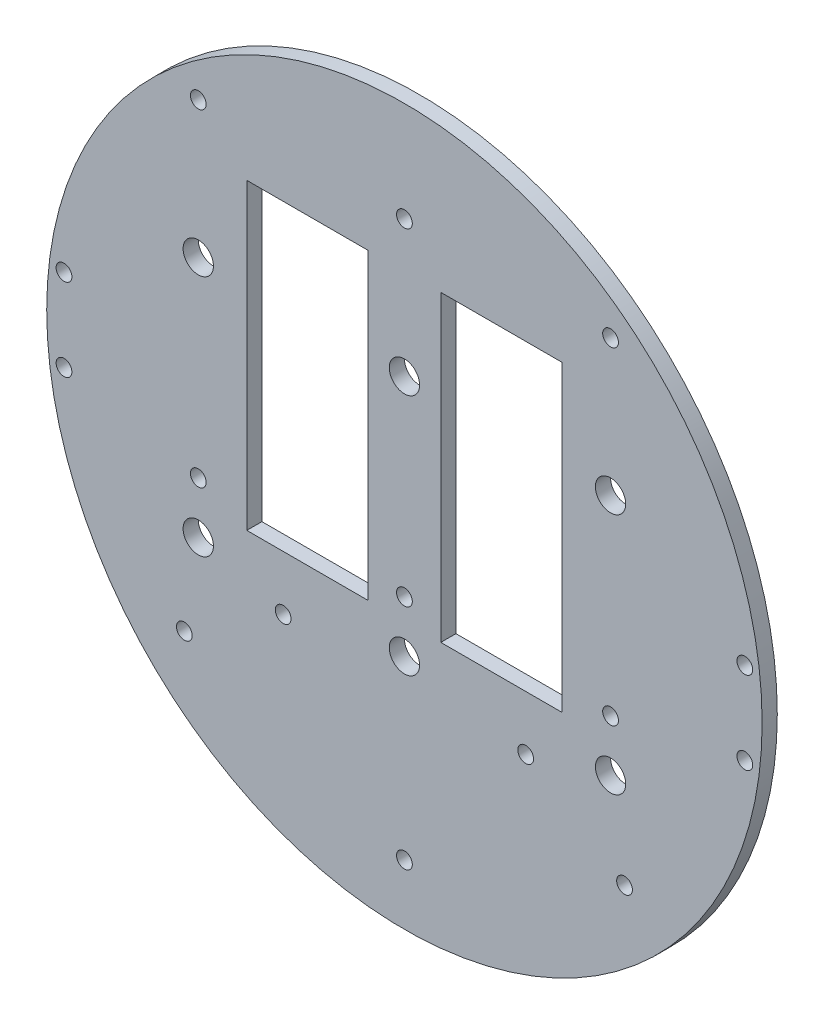
from build123d import *

# Parameters (mm, degrees)
SKETCH1_R           = 1.651
BOSS_EXTRUDE2_DEPTH = 3.175
SKETCH5_W           = 36.105919561
SKETCH5_H           = 30.801250688
SKETCH5_W_2         = 35.958513686
SKETCH5_H_2         = 33.469345806
BOSS_EXTRUDE4_DEPTH = 3.175
SKETCH11_R          = 1.651
CUT_EXTRUDE7_DEPTH  = 4.175
BOSS_EXTRUDE6_DEPTH = 3.175
SKETCH13_R          = 3.175
CUT_EXTRUDE8_DEPTH  = 21.59
SKETCH14_W          = 25.4
SKETCH14_H          = 63.5
CUT_EXTRUDE9_DEPTH  = 46.482
SKETCH15_R          = 1.651
CUT_EXTRUDE10_DEPTH = 150.876


with BuildPart() as part:
    # Sketch1 → Boss-Extrude2 (new body)
    with BuildSketch(Plane.XY):
        with BuildLine():
            Line((-73.845886141, 12.7), (-56.065886141, 12.7))
            Line((-56.065886141, 12.7), (-56.065886141, -12.7))
            Line((-56.065886141, -12.7), (-73.845886141, -12.7))
            ThreePointArc((-73.845886141, -12.7), (0, -74.93), (73.845886141, -12.7))
            Line((73.845886141, -12.7), (56.065886141, -12.7))
            Line((56.065886141, -12.7), (56.065886141, 12.7))
            Line((56.065886141, 12.7), (73.845886141, 12.7))
            ThreePointArc((73.845886141, 12.7), (0, 74.93), (-73.845886141, 12.7))
        make_face()
        with Locations((-45.466, 11.049)):
            Circle(SKETCH1_R, mode=Mode.SUBTRACT)
        with Locations((-20.067270032, 10.795)):
            Circle(SKETCH1_R, mode=Mode.SUBTRACT)
        with Locations((-20.067270032, -10.795)):
            Circle(SKETCH1_R, mode=Mode.SUBTRACT)
        with Locations((-45.466, -11.049)):
            Circle(SKETCH1_R, mode=Mode.SUBTRACT)
        with Locations((45.466, -11.049)):
            Circle(SKETCH1_R, mode=Mode.SUBTRACT)
        with Locations((20.067270032, -10.795)):
            Circle(SKETCH1_R, mode=Mode.SUBTRACT)
        with Locations((20.067270032, 10.795)):
            Circle(SKETCH1_R, mode=Mode.SUBTRACT)
        with Locations((45.466, 11.049)):
            Circle(SKETCH1_R, mode=Mode.SUBTRACT)
    extrude(amount=BOSS_EXTRUDE2_DEPTH)

    # Sketch5 → Boss-Extrude4 (add)
    with BuildSketch(Plane(origin=(0, 0, 0), x_dir=(-1, 0, 0), z_dir=(0, 0, -1))):
        with Locations((34.78484389, -0.38515144)):
            Rectangle(SKETCH5_W, SKETCH5_H)
        with Locations((-32.830563904, 0.948896119)):
            Rectangle(SKETCH5_W_2, SKETCH5_H_2)
    extrude(amount=-BOSS_EXTRUDE4_DEPTH)

    # Sketch11 → Cut-Extrude7 (cut, through all)
    with BuildSketch(Plane(origin=(0, 0, 0), x_dir=(-1, 0, 0), z_dir=(0, 0, -1))):
        with Locations((43.18, 53.975)):
            Circle(SKETCH11_R)
        with Locations((0, 53.975)):
            Circle(SKETCH11_R)
        with Locations((0, -14.605)):
            Circle(SKETCH11_R)
        with Locations((43.18, -14.605)):
            Circle(SKETCH11_R)
        with Locations((-43.18, 53.975)):
            Circle(SKETCH11_R)
        with Locations((-43.18, -14.605)):
            Circle(SKETCH11_R)
        with Locations((-25.4, -30.48)):
            Circle(SKETCH11_R)
        with Locations((-46.101, -43.8609994)):
            Circle(SKETCH11_R)
        with Locations((46.101, -43.8609994)):
            Circle(SKETCH11_R)
        with Locations((0, -62.3219988)):
            Circle(SKETCH11_R)
        with Locations((25.4, -30.48)):
            Circle(SKETCH11_R)
    extrude(amount=-CUT_EXTRUDE7_DEPTH, mode=Mode.SUBTRACT)

    # Sketch12 → Boss-Extrude6 (add)
    with BuildSketch(Plane(origin=(0, 0, 0), x_dir=(-1, 0, 0), z_dir=(0, 0, -1))):
        with BuildLine():
            Line((-54.995250635, 50.892310889), (-54.566459663, -51.351790425))
            ThreePointArc((-54.566459663, -51.351790425), (-74.929341077, -0.314238422), (-54.995250635, 50.892310889))
        make_face()
        with BuildLine():
            Line((54.995250635, 50.892310889), (54.995250635, -50.892310889))
            ThreePointArc((54.995250635, -50.892310889), (74.93, 0), (54.995250635, 50.892310889))
        make_face()
    extrude(amount=-BOSS_EXTRUDE6_DEPTH)

    # Sketch13 → Cut-Extrude8 (cut)
    with BuildSketch(Plane(origin=(0, 0, 0), x_dir=(-1, 0, 0), z_dir=(0, 0, -1))):
        with Locations((0, 25.4)):
            Circle(SKETCH13_R)
        with Locations((43.18, 25.4)):
            Circle(SKETCH13_R)
        with Locations((-43.18, 25.4)):
            Circle(SKETCH13_R)
        with Locations((-43.18, -25.4)):
            Circle(SKETCH13_R)
        with Locations((0, -25.4)):
            Circle(SKETCH13_R)
        with Locations((43.18, -25.4)):
            Circle(SKETCH13_R)
    extrude(amount=-CUT_EXTRUDE8_DEPTH, mode=Mode.SUBTRACT)

    # Sketch14 → Cut-Extrude9 (cut)
    with BuildSketch(Plane(origin=(0, 0, 0), x_dir=(-1, 0, 0), z_dir=(0, 0, -1))):
        with Locations((-20.32, 12.7)):
            Rectangle(SKETCH14_W, SKETCH14_H)
        with Locations((20.32, 12.7)):
            Rectangle(SKETCH14_W, SKETCH14_H)
    extrude(amount=-CUT_EXTRUDE9_DEPTH, mode=Mode.SUBTRACT)

    # Sketch15 → Cut-Extrude10 (cut)
    with BuildSketch(Plane(origin=(-30.092005081, 4.08352975, -73.025), x_dir=(-1, 0, 0), z_dir=(0, 0, -1))):
        with Locations((-101.395980802, -12.71952975)):
            Circle(SKETCH15_R)
        with Locations((-101.395980802, 4.55247025)):
            Circle(SKETCH15_R)
        with Locations((41.211970641, -12.71952975)):
            Circle(SKETCH15_R)
        with Locations((41.211970641, 4.55247025)):
            Circle(SKETCH15_R)
    extrude(amount=-CUT_EXTRUDE10_DEPTH, mode=Mode.SUBTRACT)


solid = part.part
